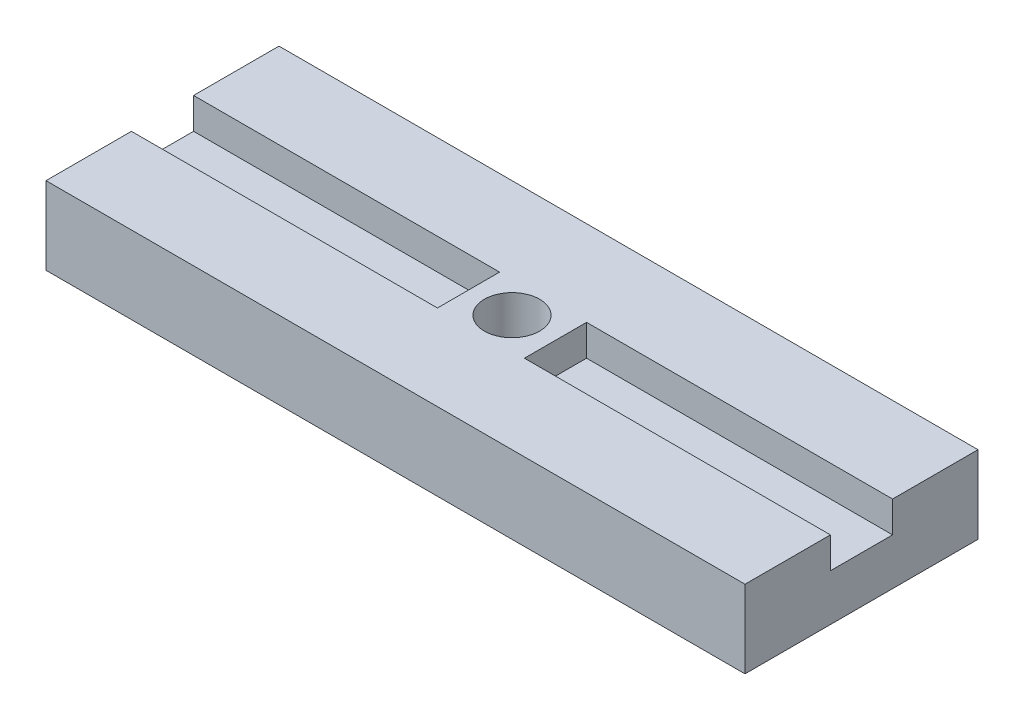
from build123d import *

# Parameters (mm, degrees)
SKETCH1_W                 = 28.575
SKETCH1_H                 = 9.525
BOSS_EXTRUDE1_DEPTH       = 3.175
F_4_40_TAPPED_HOLE1_D     = 2.2606
F_4_40_TAPPED_HOLE1_DEPTH = 7.5946
F_4_40_TAPPED_HOLE1_TIP   = 0.679152758
SKETCH5_W                 = 12.5095
SKETCH5_H                 = 2.54
CUT_EXTRUDE2_DEPTH        = 1.27


with BuildPart() as part:
    # Sketch1 → Boss-Extrude1 (new body)
    with BuildSketch(Plane(origin=(0, 0, 0), x_dir=(1, 0, 0), z_dir=(0, 1, 0))):
        Rectangle(SKETCH1_W, SKETCH1_H)
    extrude(amount=BOSS_EXTRUDE1_DEPTH)

    # #4-40 Tapped Hole1
    with Locations(Plane(origin=(0, 3.175, 0), x_dir=(1, 0, 0), z_dir=(0, 1, 0))):
        with Locations((0, 0)):
            Hole(F_4_40_TAPPED_HOLE1_D / 2, depth=F_4_40_TAPPED_HOLE1_DEPTH)
            with Locations((0, 0, -(F_4_40_TAPPED_HOLE1_DEPTH + F_4_40_TAPPED_HOLE1_TIP / 2))):  # 118° drill point
                Cone(0, F_4_40_TAPPED_HOLE1_D / 2, F_4_40_TAPPED_HOLE1_TIP, mode=Mode.SUBTRACT)

    # Sketch5 → Cut-Extrude2 (cut)
    with BuildSketch(Plane(origin=(0, 3.175, 0), x_dir=(1, 0, 0), z_dir=(0, 1, 0))):
        with Locations((-8.03275, 0)):
            Rectangle(SKETCH5_W, SKETCH5_H)
        with Locations((8.03275, 0)):
            Rectangle(SKETCH5_W, SKETCH5_H)
    extrude(amount=-CUT_EXTRUDE2_DEPTH, mode=Mode.SUBTRACT)


solid = part.part
